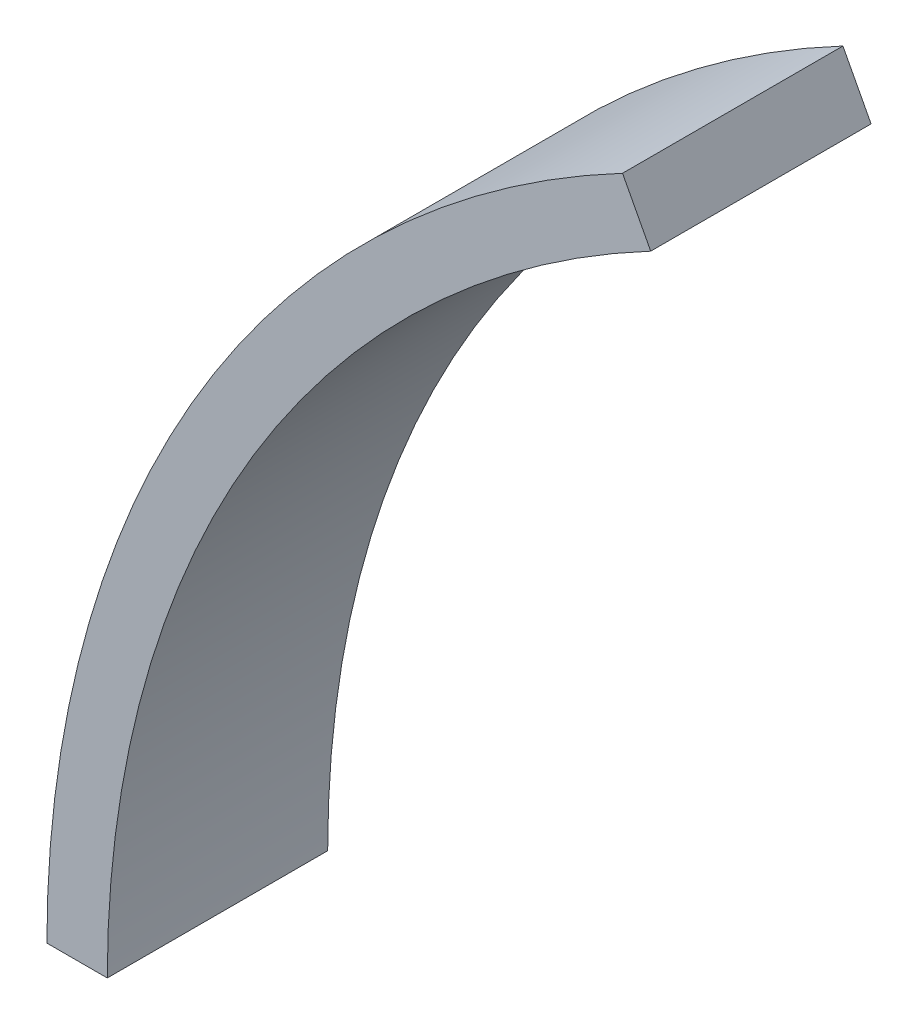
from build123d import *

# Parameters (mm, degrees)
BOSS_EXTRUDE1_DEPTH = 4.6355


with BuildPart() as part:
    # Sketch1 → Boss-Extrude1 (new body, symmetric)
    with BuildSketch(Plane.XY):
        with BuildLine():
            Line((-42.8625, 0), (-45.4025, 0))
            ThreePointArc((-45.4025, 0), (-38.880378144, 23.445750183), (-21.187833333, 40.155481878))
            Line((-21.187833333, 40.155481878), (-20.0025, 37.909021354))
            ThreePointArc((-20.0025, 37.909021354), (-36.705252094, 22.134099824), (-42.8625, 0))
        make_face()
    extrude(amount=BOSS_EXTRUDE1_DEPTH, both=True)


solid = part.part
